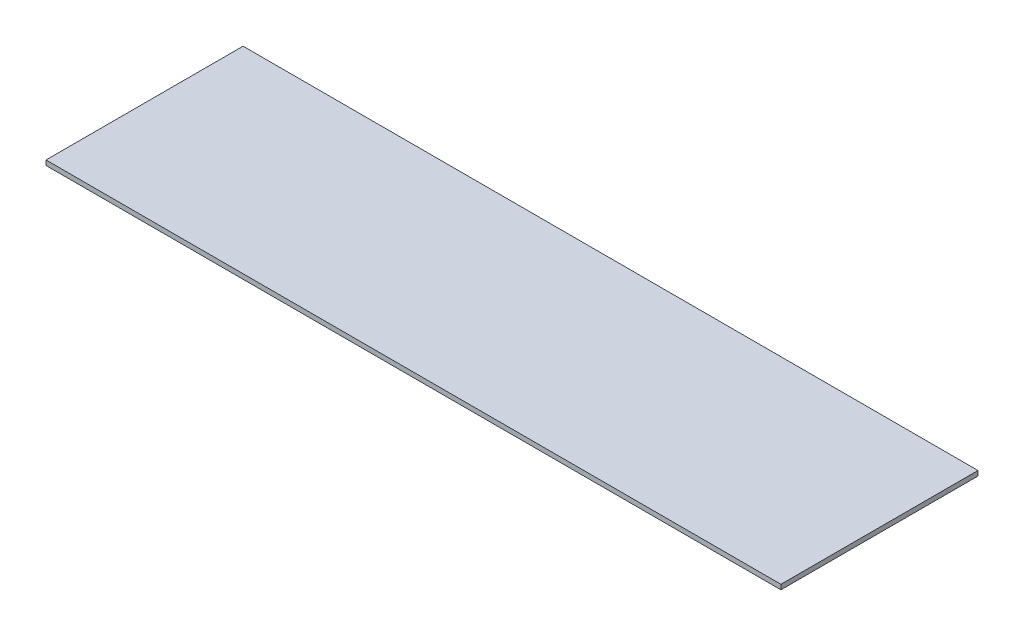
from build123d import *

# Parameters (mm, degrees)
SKETCH1_W           = 242.4
SKETCH1_H           = 65
BOSS_EXTRUDE1_DEPTH = 1.5875


with BuildPart() as part:
    # Sketch1 → Boss-Extrude1 (new body)
    with BuildSketch(Plane(origin=(0, 0, 0), x_dir=(1, 0, 0), z_dir=(0, 1, 0))):
        with Locations((121.2, 32.5)):
            Rectangle(SKETCH1_W, SKETCH1_H)
    extrude(amount=BOSS_EXTRUDE1_DEPTH)


solid = part.part
